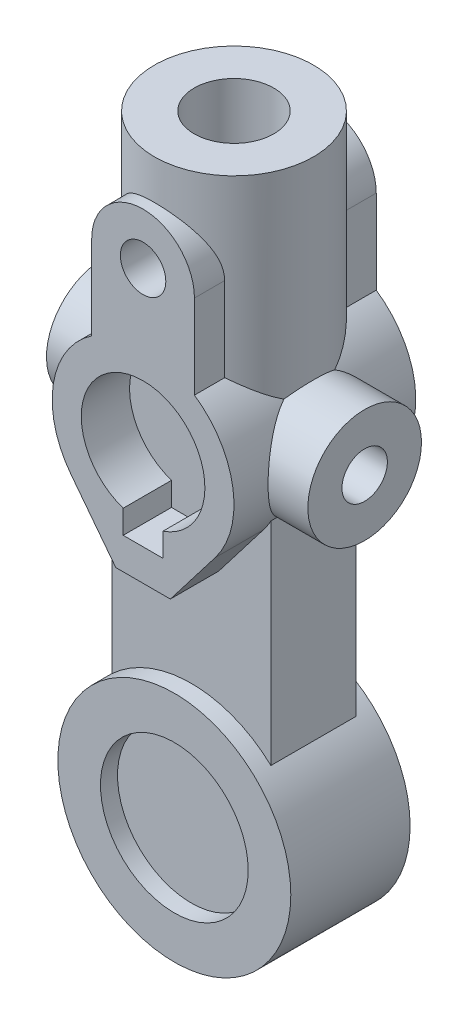
from build123d import *

# Parameters (mm, degrees)
CROQUIS1_R              = 6.35
SALIENTE_EXTRUIR1_DEPTH = 25.4
SALIENTE_EXTRUIR2_REACH = 103.6
CROQUIS2_R              = 22.225
CROQUIS2_R_2            = 11.1125
CORTAR_EXTRUIR1_REACH   = 103.6
CROQUIS3_R              = 11.1125
CROQUIS4_R              = 32.54375
CROQUIS4_R_2            = 20.6375
SALIENTE_EXTRUIR3_DEPTH = 16.66875
SALIENTE_EXTRUIR4_DEPTH = 11.90625
SALIENTE_EXTRUIR5_START = -15.451935
CROQUIS6_R              = 15.875
CROQUIS6_R_2            = 6.35
SALIENTE_EXTRUIR5_DEPTH = 15.451935
CORTAR_EXTRUIR4_START   = -61.9125
CROQUIS7_R              = 6.35
CORTAR_EXTRUIR4_DEPTH   = 50.8


with BuildPart() as part:
    # Croquis1 → Saliente-Extruir1 (new body, symmetric)
    with BuildSketch(Plane.XY):
        with BuildLine():
            Line((-14.351, 44.45), (-14.351, 20.957308964))
            ThreePointArc((-14.351, 20.957308964), (-25.086456553, 3.978655251), (-20.131223839, -15.488506279))
            Line((-20.131223839, -15.488506279), (-7.62, -31.75))
            Line((-7.62, -31.75), (7.62, -31.75))
            Line((7.62, -31.75), (20.131223839, -15.488506279))
            ThreePointArc((20.131223839, -15.488506279), (25.086456553, 3.978655251), (14.351, 20.957308964))
            Line((14.351, 20.957308964), (14.351, 44.45))
            ThreePointArc((14.351, 44.45), (0, 58.801), (-14.351, 44.45))
        make_face()
        with Locations((0, 44.45)):
            Circle(CROQUIS1_R, mode=Mode.SUBTRACT)
        with BuildLine():
            Line((-5.55625, -22.91842), (5.55625, -22.91842))
            Line((5.55625, -22.91842), (5.55625, -16.353900756))
            ThreePointArc((5.55625, -16.353900756), (0, 17.272), (-5.55625, -16.353900756))
            Line((-5.55625, -16.353900756), (-5.55625, -22.91842))
        make_face(mode=Mode.SUBTRACT)
    extrude(amount=SALIENTE_EXTRUIR1_DEPTH, both=True)

    # Croquis2 → Saliente-Extruir2 (add, up to next)
    with BuildSketch(Plane(origin=(0, 69.85, 0), x_dir=(1, 0, 0), z_dir=(0, 1, 0)), mode=Mode.PRIVATE) as saliente_extruir2_sk1:
        Circle(CROQUIS2_R)
        Circle(CROQUIS2_R_2, mode=Mode.SUBTRACT)
    saliente_extruir2_tool1 = extrude(saliente_extruir2_sk1.sketch, amount=-SALIENTE_EXTRUIR2_REACH, mode=Mode.PRIVATE) - part.part
    add(saliente_extruir2_tool1.solids().sort_by_distance((-21.596382, 69.85, 0))[0])

    # Croquis3 → Cortar-Extruir1 (cut, up to next)
    with BuildSketch(Plane(origin=(0, 69.85, 0), x_dir=(1, 0, 0), z_dir=(0, 1, 0)), mode=Mode.PRIVATE) as cortar_extruir1_sk1:
        Circle(CROQUIS3_R)
    cortar_extruir1_tool1 = extrude(cortar_extruir1_sk1.sketch, amount=-CORTAR_EXTRUIR1_REACH, mode=Mode.PRIVATE) & part.part
    add(cortar_extruir1_tool1.solids().sort_by_distance((0, 69.85, 0))[0], mode=Mode.SUBTRACT)



with BuildPart() as body_2:
    # Croquis4 → Saliente-Extruir3 (new body, symmetric)
    with BuildSketch(Plane.XY):
        with Locations((0, -95.25)):
            Circle(CROQUIS4_R)
        with Locations((0, -95.25)):
            Circle(CROQUIS4_R_2, mode=Mode.SUBTRACT)
    extrude(amount=SALIENTE_EXTRUIR3_DEPTH, both=True)


with BuildPart() as part_1:
    add(part.part)

    add(body_2.part)  # Saliente-Extruir4 merges body 2
    # Croquis5 → Saliente-Extruir4 (add, symmetric)
    with BuildSketch(Plane.XY):
        with BuildLine():
            Line((-22.225, -12.296722124), (-22.225, -71.477220628))
            ThreePointArc((-22.225, -71.477220628), (0, -127.79375), (22.225, -71.477220628))
            Line((22.225, -71.477220628), (22.225, -12.296722124))
            ThreePointArc((22.225, -12.296722124), (0, 25.4), (-22.225, -12.296722124))
        make_face()
    extrude(amount=SALIENTE_EXTRUIR4_DEPTH, both=True)

    # Croquis6 → Saliente-Extruir5 (add)
    with BuildSketch(Plane(origin=(36.5125, 0, 0), x_dir=(0, 0, -1), z_dir=(1, 0, 0)).offset(SALIENTE_EXTRUIR5_START)):
        Circle(CROQUIS6_R)
        Circle(CROQUIS6_R_2, mode=Mode.SUBTRACT)
    saliente_extruir5 = extrude(amount=SALIENTE_EXTRUIR5_DEPTH)

    # Croquis7 → Cortar-Extruir4 (cut)
    with BuildSketch(Plane(origin=(36.5125, 0, 0), x_dir=(0, 0, -1), z_dir=(1, 0, 0)).offset(CORTAR_EXTRUIR4_START)):
        Circle(CROQUIS7_R)
    cortar_extruir4 = extrude(amount=CORTAR_EXTRUIR4_DEPTH, mode=Mode.SUBTRACT)

    # Simetría1: Saliente-Extruir5, Cortar-Extruir4 across plane
    add(saliente_extruir5.mirror(Plane(origin=(0, 0, 0), x_dir=(0, 0, 1), z_dir=(1, 0, 0))))
    add(cortar_extruir4.mirror(Plane(origin=(0, 0, 0), x_dir=(0, 0, 1), z_dir=(1, 0, 0))), mode=Mode.SUBTRACT)


solid = part_1.part
